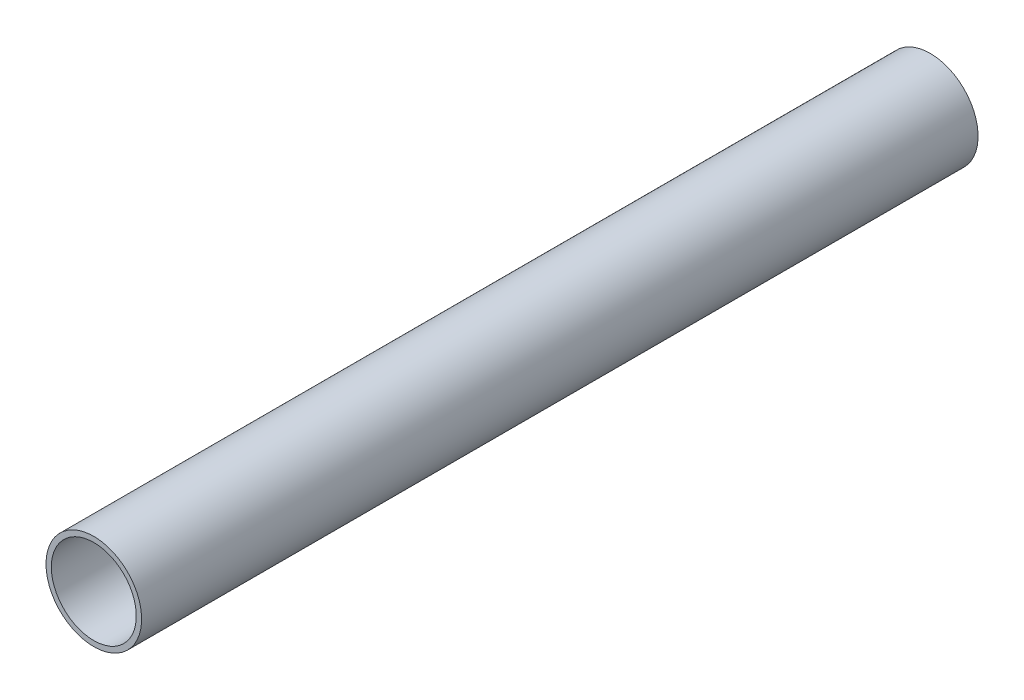
from build123d import *

# Parameters (mm, degrees)
SKETCH_1_W = 6.35
SKETCH_1_H = 1000


with BuildPart() as part:
    # 草图1 → 旋转1 (revolve)
    with BuildSketch(Plane.XZ):
        with Locations((53.975, 25)):
            Rectangle(SKETCH_1_W, SKETCH_1_H)
    revolve(axis=Axis((0, 0, 475), (0, 0, -1)))


solid = part.part
